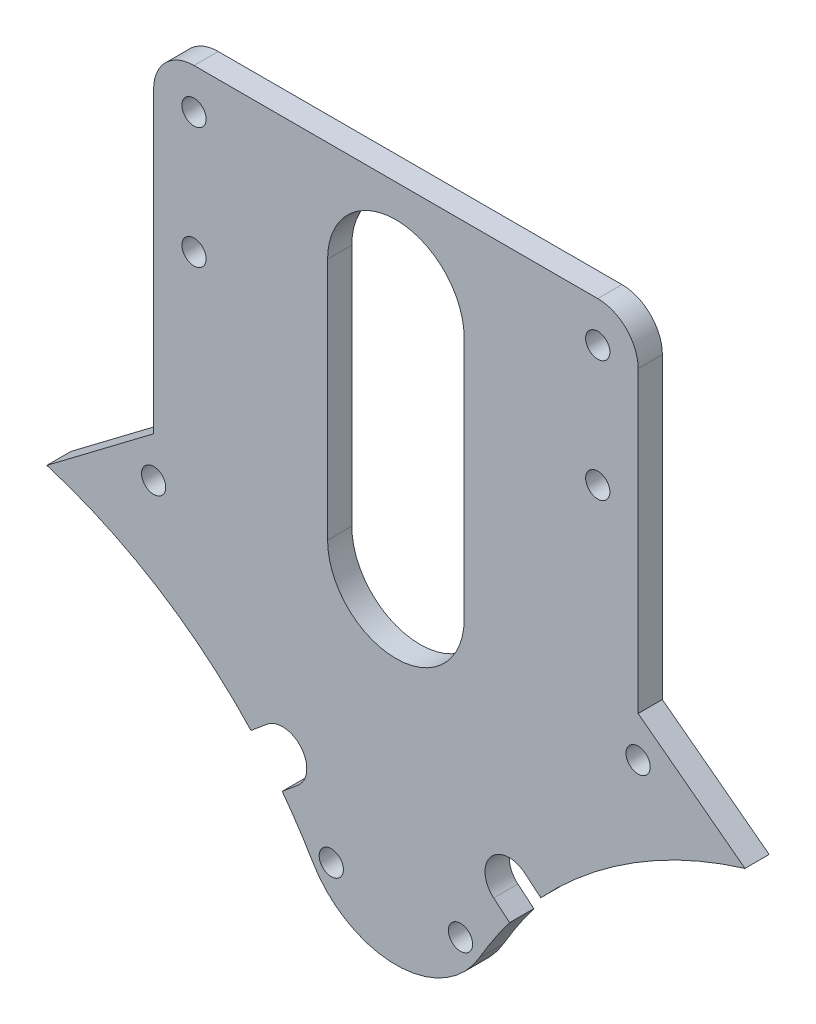
from build123d import *

# Parameters (mm, degrees)
SKETCH_1_R          = 1.5
EXTRUDE_1_DEPTH     = 3
CUT_EXTRUDE_1_DEPTH = 10
SKETCH_3_R          = 1.5
CUT_EXTRUDE_2_DEPTH = 10
SKETCH_4_R          = 1
SKETCH_4_W          = 12.5
SKETCH_4_H          = 22.5
EXTRUDE_2_DEPTH     = 3
SKETCH_5_R          = 1
CUT_EXTRUDE_3_DEPTH = 10
FILLET_1_R          = 10
CUT_EXTRUDE_4_DEPTH = 10
FILLET_2_R          = 5


with BuildPart() as part:
    # 草图1 → 凸台-拉伸1 (new body)
    with BuildSketch(Plane.XY):
        with BuildLine():
            Line((30, 65), (43.229490169, 55))
            ThreePointArc((43.229490169, 55), (24.322951332, 45.093216766), (10.332713198, 28.972583968))
            ThreePointArc((10.332713198, 28.972583968), (0, 23.037780053), (-10.332713198, 28.972583968))
            ThreePointArc((-10.332713198, 28.972583968), (-24.322951332, 45.093216766), (-43.229490169, 55))
            Line((-43.229490169, 55), (-30, 65))
            Line((-30, 65), (-30, 107))
            ThreePointArc((-30, 107), (-27.071067812, 114.071067812), (-20, 117))
            Line((-20, 117), (20, 117))
            ThreePointArc((20, 117), (27.071067812, 114.071067812), (30, 107))
            Line((30, 107), (30, 65))
        make_face()
        with Locations((-30, 60)):
            Circle(SKETCH_1_R, mode=Mode.SUBTRACT)
        with Locations((-8, 30)):
            Circle(SKETCH_1_R, mode=Mode.SUBTRACT)
        with Locations((8, 30)):
            Circle(SKETCH_1_R, mode=Mode.SUBTRACT)
        with Locations((30, 60)):
            Circle(SKETCH_1_R, mode=Mode.SUBTRACT)
    extrude(amount=EXTRUDE_1_DEPTH)

    # 草图2 → 切除-拉伸1 (cut)
    with BuildSketch(Plane(origin=(0, 0, 0), x_dir=(-1, 0, 0), z_dir=(0, 0, -1))):
        with BuildLine():
            Line((14.08407385, 34.61181483), (12.108970584, 36.269123252))
            ThreePointArc((12.108970584, 36.269123252), (11.739200084, 40.49561941), (15.965696242, 40.865389911))
            Line((15.965696242, 40.865389911), (17.940799508, 39.208081488))
            Line((17.940799508, 39.208081488), (18.60524138, 38.39769253))
            Line((18.60524138, 38.39769253), (14.816805035, 33.83995685))
            Line((14.816805035, 33.83995685), (14.08407385, 34.61181483))
        make_face()
        with BuildLine():
            Line((-18.60524138, 38.39769253), (-17.940799508, 39.208081488))
            Line((-17.940799508, 39.208081488), (-15.965696242, 40.865389911))
            ThreePointArc((-15.965696242, 40.865389911), (-11.739200084, 40.49561941), (-12.108970584, 36.269123252))
            Line((-12.108970584, 36.269123252), (-14.08407385, 34.61181483))
            Line((-14.08407385, 34.61181483), (-14.816805035, 33.83995685))
            Line((-14.816805035, 33.83995685), (-18.60524138, 38.39769253))
        make_face()
    extrude(amount=-CUT_EXTRUDE_1_DEPTH, mode=Mode.SUBTRACT)

    # 草图3 → 切除-拉伸2 (cut)
    with BuildSketch(Plane(origin=(0, 0, 0), x_dir=(-1, 0, 0), z_dir=(0, 0, -1))):
        with Locations((-25, 102)):
            Circle(SKETCH_3_R)
        with Locations((-25, 87)):
            Circle(SKETCH_3_R)
        with Locations((25, 102)):
            Circle(SKETCH_3_R)
        with Locations((25, 87)):
            Circle(SKETCH_3_R)
        with BuildLine():
            Line((-8.458896236, 64.355158964), (-8.458896236, 94.5))
            ThreePointArc((-8.458896236, 94.5), (0, 102.958896236), (8.458896236, 94.5))
            Line((8.458896236, 94.5), (8.458896236, 64.355158964))
            ThreePointArc((8.458896236, 64.355158964), (0, 55.896262728), (-8.458896236, 64.355158964))
        make_face()
    extrude(amount=-CUT_EXTRUDE_2_DEPTH, mode=Mode.SUBTRACT)

    # 草图4 → 凸台-拉伸2 (add)
    with BuildSketch(Plane(origin=(0, 0, 0), x_dir=(-1, 0, 0), z_dir=(0, 0, -1))):
        with BuildLine():
            Line((-9.51564662, 141.75), (-20, 117))
            Line((-20, 117), (-9.51564662, 117))
            Line((-9.51564662, 117), (-2.844735856, 108.972139798))
            Line((-2.844735856, 108.972139798), (9.51564662, 117))
            Line((9.51564662, 117), (20, 117))
            Line((20, 117), (9.51564662, 141.75))
            ThreePointArc((9.51564662, 141.75), (0, 151.26564662), (-9.51564662, 141.75))
        make_face()
        with Locations((0, 141.75)):
            Circle(SKETCH_4_R, mode=Mode.SUBTRACT)
        with Locations((0, 128.25)):
            Rectangle(SKETCH_4_W, SKETCH_4_H, mode=Mode.SUBTRACT)
    extrude(amount=-EXTRUDE_2_DEPTH)

    # 草图5 → 切除-拉伸3 (cut)
    with BuildSketch(Plane(origin=(0, 0, 0), x_dir=(-1, 0, 0), z_dir=(0, 0, -1))):
        with Locations((0, 114.75)):
            Circle(SKETCH_5_R)
    extrude(amount=-CUT_EXTRUDE_3_DEPTH, mode=Mode.SUBTRACT)

    # 圆角1
    fillet_1_edges = [part.edges().sort_by_distance(p)[0] for p in [
        (9.51564662, 141.75, 1.5),
        (-9.51564662, 141.75, 1.5),
        (-20, 117, 1.5),
        (20, 117, 1.5),
    ]]
    fillet(fillet_1_edges, radius=FILLET_1_R)

    # 草图6 → 切除-拉伸4 (cut)
    with BuildSketch(Plane(origin=(0, 0, 0), x_dir=(-1, 0, 0), z_dir=(0, 0, -1))):
        Polygon((-30, 107), (30, 107), (76.168650248, 160.022811959), (-16.915973461, 154.626601889), (-34.871476016, 113.990464525), align=None)
    extrude(amount=-CUT_EXTRUDE_4_DEPTH, mode=Mode.SUBTRACT)

    # 圆角2
    fillet_2_edges = [part.edges().sort_by_distance(p)[0] for p in [
        (30, 107, 1.5),
        (-30, 107, 1.5),
    ]]
    fillet(fillet_2_edges, radius=FILLET_2_R)


solid = part.part
